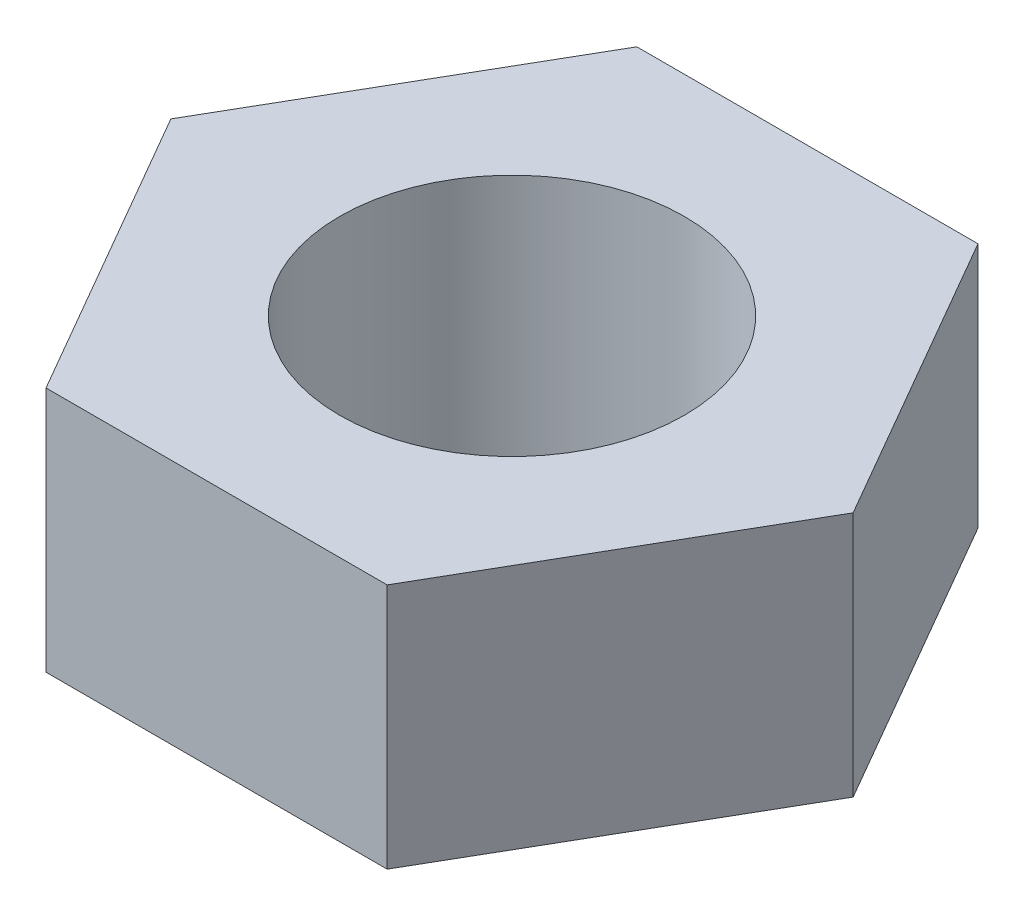
from build123d import *

# Parameters (mm, degrees)
SKETCH1_R           = 7
BOSS_EXTRUDE1_DEPTH = 10


with BuildPart() as part:
    # Sketch1 → Boss-Extrude1 (new body)
    with BuildSketch(Plane(origin=(0, 0, 0), x_dir=(1, 0, 0), z_dir=(0, 1, 0))):
        Polygon((13.856406461, 0), (6.92820323, 12), (-6.92820323, 12), (-13.856406461, 0), (-6.92820323, -12), (6.92820323, -12), align=None)
        Circle(SKETCH1_R, mode=Mode.SUBTRACT)
    extrude(amount=BOSS_EXTRUDE1_DEPTH)


solid = part.part
